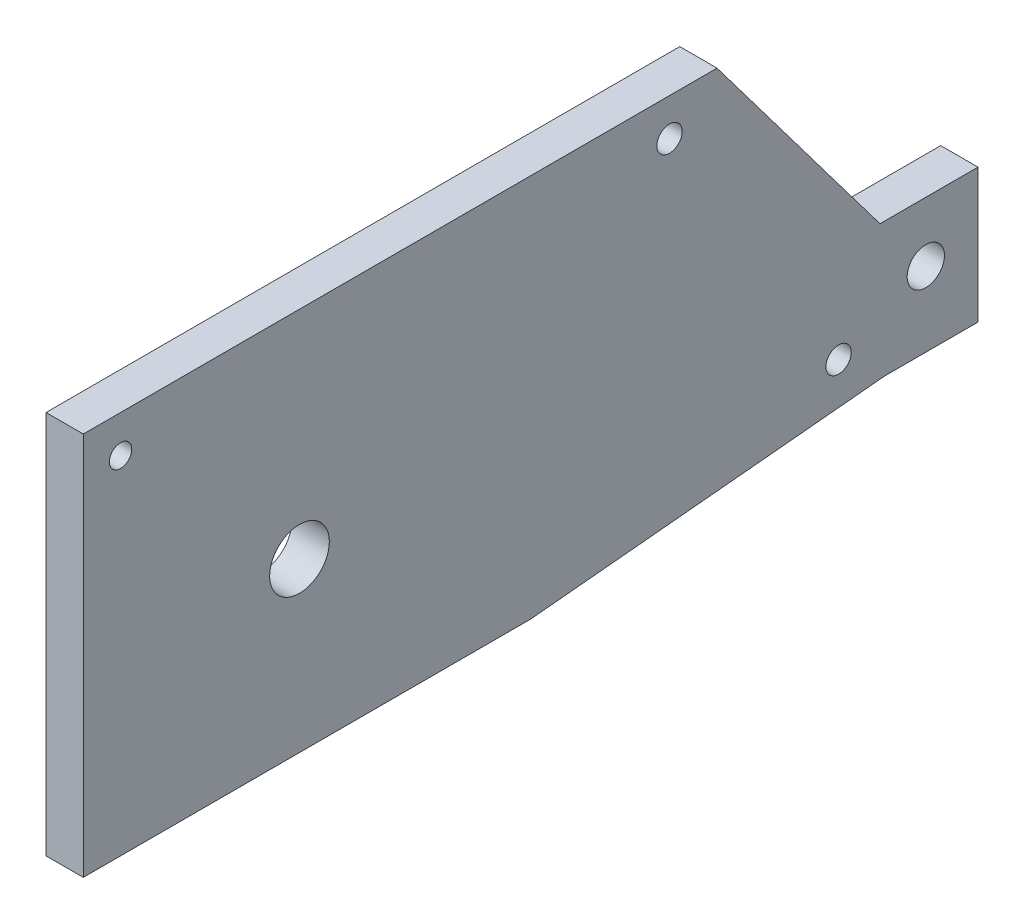
from build123d import *

# Parameters (mm, degrees)
CROQUIS1_W              = 120
CROQUIS1_H              = 51.5
SALIENTE_EXTRUIR1_DEPTH = 5
CORTAR_EXTRUIR1_REACH   = 7
CORTAR_EXTRUIR2_REACH   = 7
CROQUIS3_R              = 1.5
CROQUIS3_R_2            = 4
CORTAR_EXTRUIR3_REACH   = 7
CROQUIS4_R              = 1.7
CORTAR_EXTRUIR4_REACH   = 7
CROQUIS9_R              = 2.5
CORTAR_EXTRUIR8_DEPTH   = 10


with BuildPart() as part:
    # Croquis1 → Saliente-Extruir1 (new body)
    with BuildSketch(Plane(origin=(0, 0, 0), x_dir=(0, 0, -1), z_dir=(1, 0, 0))):
        Rectangle(CROQUIS1_W, CROQUIS1_H)
    extrude(amount=SALIENTE_EXTRUIR1_DEPTH)

    # Croquis2 → Cortar-Extruir1 (cut, up to next)
    with BuildSketch(Plane(origin=(5, 0, 0), x_dir=(0, 0, -1), z_dir=(1, 0, 0)), mode=Mode.PRIVATE) as cortar_extruir1_sk1:
        Polygon((25, 25.75), (46.853067453, -3.25), (60, -3.25), (60, 25.75), align=None)
    cortar_extruir1_tool1 = extrude(cortar_extruir1_sk1.sketch, amount=-CORTAR_EXTRUIR1_REACH, mode=Mode.PRIVATE) & part.part
    add(cortar_extruir1_tool1.solids().sort_by_distance((5, 13.443767, -47.136706))[0], mode=Mode.SUBTRACT)

    # Croquis3 → Cortar-Extruir2 (cut, up to next)
    with BuildSketch(Plane(origin=(5, 0, 0), x_dir=(0, 0, -1), z_dir=(1, 0, 0)), mode=Mode.PRIVATE) as cortar_extruir2_sk1:
        with Locations((-55, 20.75)):
            Circle(CROQUIS3_R)
    cortar_extruir2_tool1 = extrude(cortar_extruir2_sk1.sketch, amount=-CORTAR_EXTRUIR2_REACH, mode=Mode.PRIVATE) & part.part
    add(cortar_extruir2_tool1.solids().sort_by_distance((5, 20.75, 55))[0], mode=Mode.SUBTRACT)
    # Croquis3 → Cortar-Extruir2 (cut, up to next)
    with BuildSketch(Plane(origin=(5, 0, 0), x_dir=(0, 0, -1), z_dir=(1, 0, 0)), mode=Mode.PRIVATE) as cortar_extruir2_sk2:
        with Locations((-31, -3.25)):
            Circle(CROQUIS3_R_2)
    cortar_extruir2_tool2 = extrude(cortar_extruir2_sk2.sketch, amount=-CORTAR_EXTRUIR2_REACH, mode=Mode.PRIVATE) & part.part
    add(cortar_extruir2_tool2.solids().sort_by_distance((5, -3.25, 31))[0], mode=Mode.SUBTRACT)

    # Croquis4 → Cortar-Extruir3 (cut, up to next)
    with BuildSketch(Plane.ZY, mode=Mode.PRIVATE) as cortar_extruir3_sk1:
        with Locations((-18.623723721, 20.75)):
            Circle(CROQUIS4_R)
    cortar_extruir3_tool1 = extrude(cortar_extruir3_sk1.sketch, amount=-CORTAR_EXTRUIR3_REACH, mode=Mode.PRIVATE) & part.part
    add(cortar_extruir3_tool1.solids().sort_by_distance((0, 20.75, -18.623724))[0], mode=Mode.SUBTRACT)
    # Croquis4 → Cortar-Extruir3 (cut, up to next)
    with BuildSketch(Plane.ZY, mode=Mode.PRIVATE) as cortar_extruir3_sk2:
        with Locations((-41.301477372, -16.25)):
            Circle(CROQUIS4_R)
    cortar_extruir3_tool2 = extrude(cortar_extruir3_sk2.sketch, amount=-CORTAR_EXTRUIR3_REACH, mode=Mode.PRIVATE) & part.part
    add(cortar_extruir3_tool2.solids().sort_by_distance((0, -16.25, -41.301477))[0], mode=Mode.SUBTRACT)

    # Croquis5 → Cortar-Extruir4 (cut, up to next)
    with BuildSketch(Plane(origin=(5, 0, 0), x_dir=(0, 0, -1), z_dir=(1, 0, 0)), mode=Mode.PRIVATE) as cortar_extruir4_sk1:
        Polygon((47.5, -21.25), (0, -25.75), (47.5, -25.75), (60, -25.75), (60, -21.25), align=None)
    cortar_extruir4_tool1 = extrude(cortar_extruir4_sk1.sketch, amount=-CORTAR_EXTRUIR4_REACH, mode=Mode.PRIVATE) & part.part
    add(cortar_extruir4_tool1.solids().sort_by_distance((5, -23.991379, -39.281609))[0], mode=Mode.SUBTRACT)

    # Croquis9 → Cortar-Extruir8 (cut)
    with BuildSketch(Plane(origin=(5, 0, 0), x_dir=(0, 0, -1), z_dir=(1, 0, 0))):
        with Locations((53, -11.25)):
            Circle(CROQUIS9_R)
    extrude(amount=-CORTAR_EXTRUIR8_DEPTH, mode=Mode.SUBTRACT)


solid = part.part
